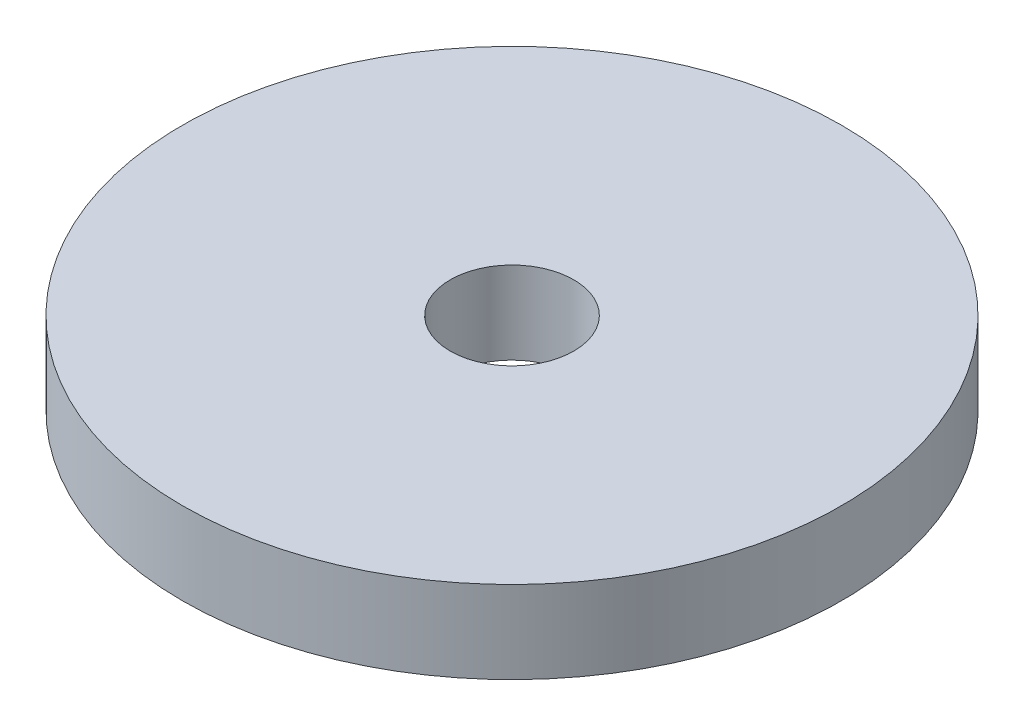
from build123d import *

# Parameters (mm, degrees)
SKETCH1_R           = 25.4
SKETCH1_R_2         = 4.7625
BOSS_EXTRUDE1_DEPTH = 6.35


with BuildPart() as part:
    # Sketch1 → Boss-Extrude1 (new body)
    with BuildSketch(Plane(origin=(0, 0, 0), x_dir=(1, 0, 0), z_dir=(0, 1, 0))):
        Circle(SKETCH1_R)
        Circle(SKETCH1_R_2, mode=Mode.SUBTRACT)
    extrude(amount=BOSS_EXTRUDE1_DEPTH)


solid = part.part
